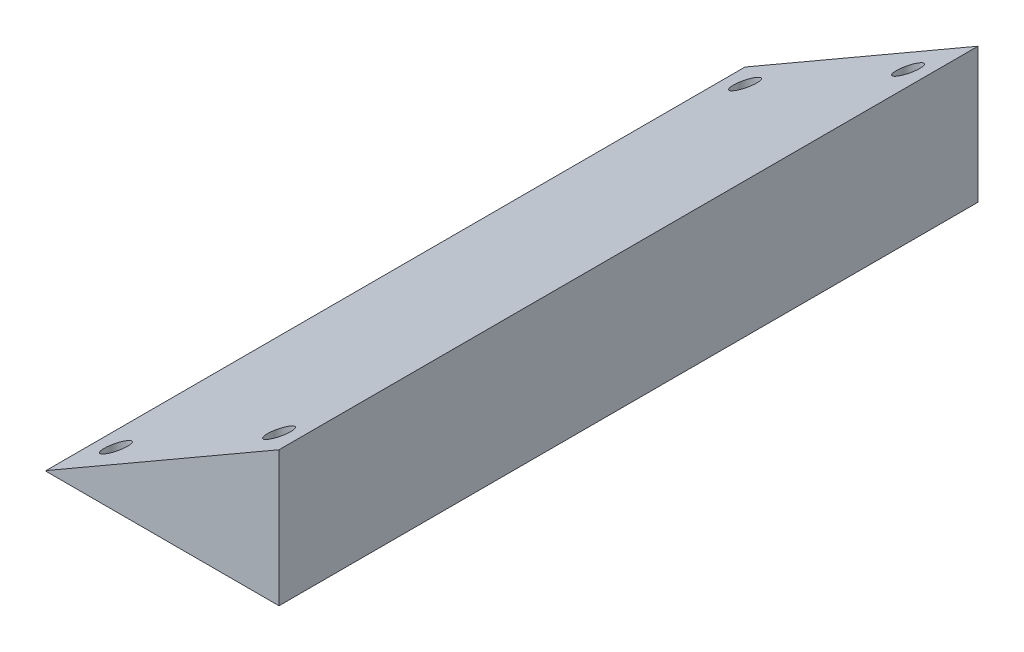
from build123d import *

# Parameters (mm, degrees)
BOSS_EXTRUDE1_DEPTH = 75
SKETCH3_R           = 2.5
CUT_EXTRUDE1_DEPTH  = 50


with BuildPart() as part:
    # Sketch2 → Boss-Extrude1 (new body, symmetric)
    with BuildSketch(Plane.XY):
        Polygon((-25, 0), (25, 0), (25, 29), (-25, 0.132486541), align=None)
    extrude(amount=BOSS_EXTRUDE1_DEPTH, both=True)

    # Sketch3 → Cut-Extrude1 (cut)
    with BuildSketch(Plane.XZ):
        with Locations((-17.5, 67.5)):
            Circle(SKETCH3_R)
        with Locations((17.5, 67.5)):
            Circle(SKETCH3_R)
        with Locations((-17.5, -67.5)):
            Circle(SKETCH3_R)
        with Locations((17.5, -67.5)):
            Circle(SKETCH3_R)
    extrude(amount=-CUT_EXTRUDE1_DEPTH, mode=Mode.SUBTRACT)


solid = part.part
